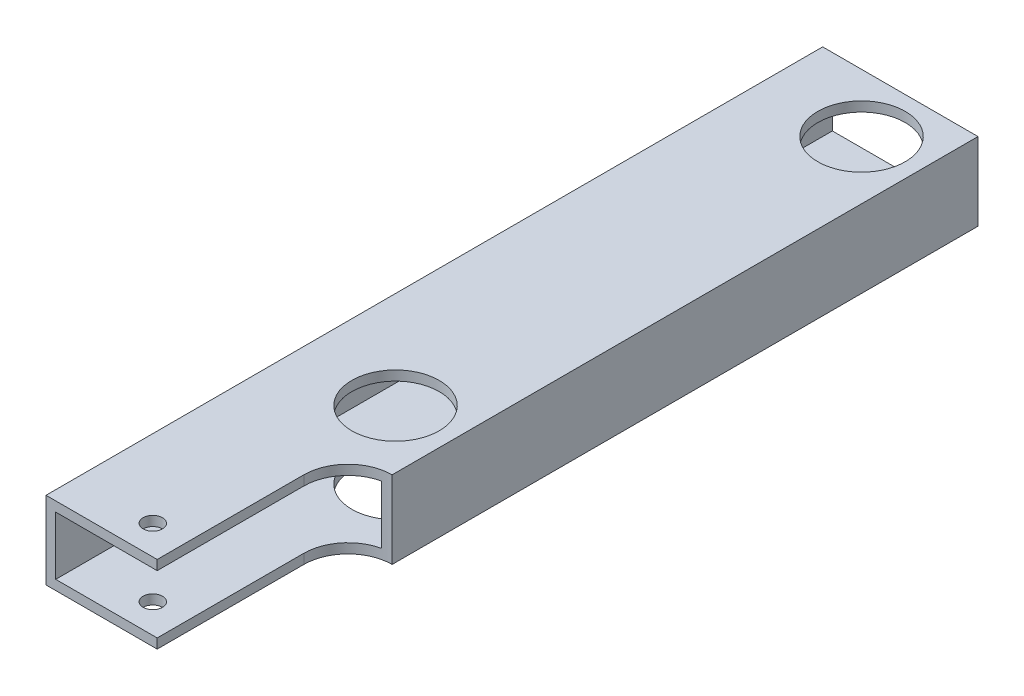
from build123d import *

# Parameters (mm, degrees)
SKETCH1_W           = 50.8
SKETCH1_H           = 25.4
SKETCH1_W_2         = 44.45
SKETCH1_H_2         = 19.05
BOSS_EXTRUDE1_DEPTH = 254
SKETCH2_R           = 14.2875
CUT_EXTRUDE1_DEPTH  = 26.4
SKETCH3_R           = 3.175
CUT_EXTRUDE2_DEPTH  = 26.4
CUT_EXTRUDE3_DEPTH  = 26.4


with BuildPart() as part:
    # Sketch1 → Boss-Extrude1 (new body)
    with BuildSketch(Plane.XY):
        with Locations((25.4, 12.7)):
            Rectangle(SKETCH1_W, SKETCH1_H)
        with Locations((25.4, 12.7)):
            Rectangle(SKETCH1_W_2, SKETCH1_H_2, mode=Mode.SUBTRACT)
    extrude(amount=BOSS_EXTRUDE1_DEPTH)

    # Sketch2 → Cut-Extrude1 (cut, through all)
    with BuildSketch(Plane(origin=(0, 25.4, 0), x_dir=(1, 0, 0), z_dir=(0, 1, 0))):
        with Locations((31.75, -19.05)):
            Circle(SKETCH2_R)
        with Locations((31.75, -171.45)):
            Circle(SKETCH2_R)
    extrude(amount=-CUT_EXTRUDE1_DEPTH, mode=Mode.SUBTRACT)

    # Sketch3 → Cut-Extrude2 (cut, through all)
    with BuildSketch(Plane(origin=(0, 25.4, 0), x_dir=(1, 0, 0), z_dir=(0, 1, 0))):
        with Locations((25.4, -244.475)):
            Circle(SKETCH3_R)
    extrude(amount=-CUT_EXTRUDE2_DEPTH, mode=Mode.SUBTRACT)

    # Sketch4 → Cut-Extrude3 (cut, through all)
    with BuildSketch(Plane(origin=(0, 25.4, 0), x_dir=(1, 0, 0), z_dir=(0, 1, 0))):
        with BuildLine():
            Line((36.358855328, -254), (36.358855328, -206.035443665))
            ThreePointArc((36.358855328, -206.035443665), (40.588568674, -195.824012339), (50.8, -191.594298992))
            Line((50.8, -191.594298992), (50.8, -254))
            Line((50.8, -254), (36.358855328, -254))
        make_face()
    extrude(amount=-CUT_EXTRUDE3_DEPTH, mode=Mode.SUBTRACT)


solid = part.part
